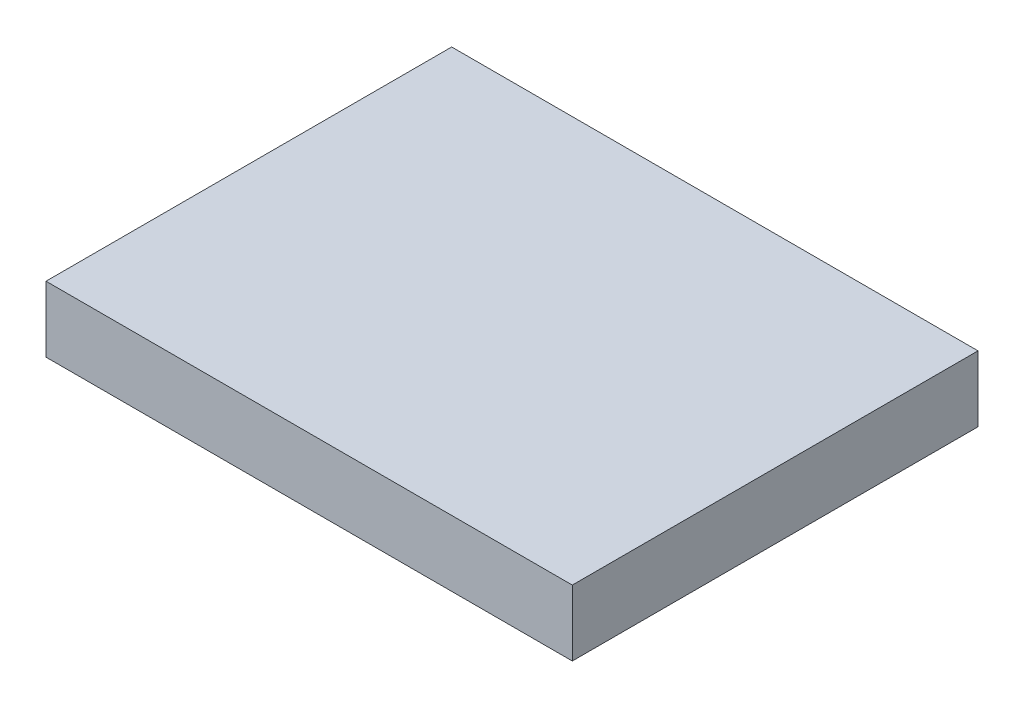
from build123d import *

# Parameters (mm, degrees)
SKETCH1_W           = 240
SKETCH1_H           = 185
BOSS_EXTRUDE1_DEPTH = 30


with BuildPart() as part:
    # Sketch1 → Boss-Extrude1 (new body)
    with BuildSketch(Plane(origin=(0, 0, 0), x_dir=(1, 0, 0), z_dir=(0, 1, 0))):
        Rectangle(SKETCH1_W, SKETCH1_H)
    extrude(amount=BOSS_EXTRUDE1_DEPTH)


solid = part.part
